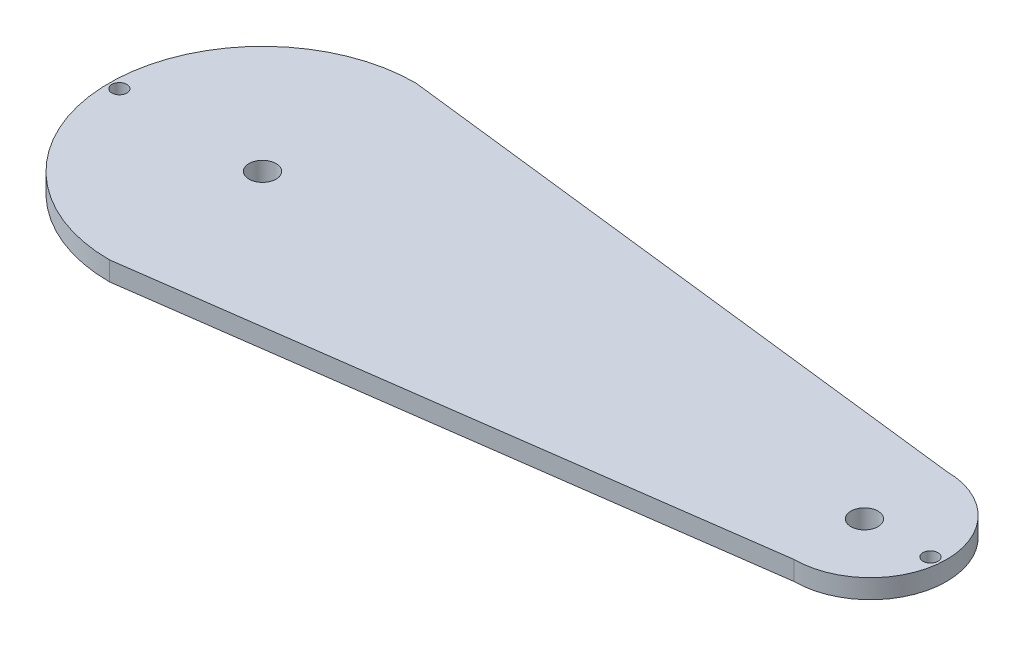
from build123d import *

# Parameters (mm, degrees)
BOSS_EXTRUDE1_DEPTH = 25.4
SKETCH3_R           = 2.5
CUT_EXTRUDE2_DEPTH  = 25.4
CUT_EXTRUDE3_DEPTH  = 19.05
SKETCH4_R           = 4.5
CUT_EXTRUDE4_DEPTH  = 19.05


with BuildPart() as part:
    # Sketch1 → Boss-Extrude1 (new body)
    with BuildSketch(Plane(origin=(0, 0, 0), x_dir=(1, 0, 0), z_dir=(0, 1, 0))):
        with BuildLine():
            Line((0, 50.892363224), (200.000108, 27.30276997))
            ThreePointArc((200.000108, 27.30276997), (225.337078532, 1.965799438), (200.000108, -23.371171094))
            Line((200.000108, -23.371171094), (0, -50.892363224))
            ThreePointArc((0, -50.892363224), (-50.892363224, 0), (0, 50.892363224))
        make_face()
    extrude(amount=BOSS_EXTRUDE1_DEPTH)

    # Sketch3 → Cut-Extrude2 (cut)
    with BuildSketch(Plane(origin=(0, 25.4, 0), x_dir=(1, 0, 0), z_dir=(0, 1, 0))):
        with Locations((-47.56908022, 0)):
            Circle(SKETCH3_R)
        with Locations((221.926143204, 0)):
            Circle(SKETCH3_R)
    extrude(amount=-CUT_EXTRUDE2_DEPTH, mode=Mode.SUBTRACT)

    # Sketch1_3 → Cut-Extrude3 (cut)
    with BuildSketch(Plane(origin=(0, 0, 0), x_dir=(1, 0, 0), z_dir=(0, 1, 0))):
        with BuildLine():
            Line((0, 50.892363224), (200.000108, 27.30276997))
            ThreePointArc((200.000108, 27.30276997), (225.337078532, 1.965799438), (200.000108, -23.371171094))
            Line((200.000108, -23.371171094), (0, -50.892363224))
            ThreePointArc((0, -50.892363224), (-50.892363224, 0), (0, 50.892363224))
        make_face()
    extrude(amount=CUT_EXTRUDE3_DEPTH, mode=Mode.SUBTRACT)

    # Sketch4 → Cut-Extrude4 (cut)
    with BuildSketch(Plane(origin=(0, 25.4, 0), x_dir=(1, 0, 0), z_dir=(0, 1, 0))):
        Circle(SKETCH4_R)
        with Locations((200.000108, 0)):
            Circle(SKETCH4_R)
    extrude(amount=-CUT_EXTRUDE4_DEPTH, mode=Mode.SUBTRACT)


solid = part.part
